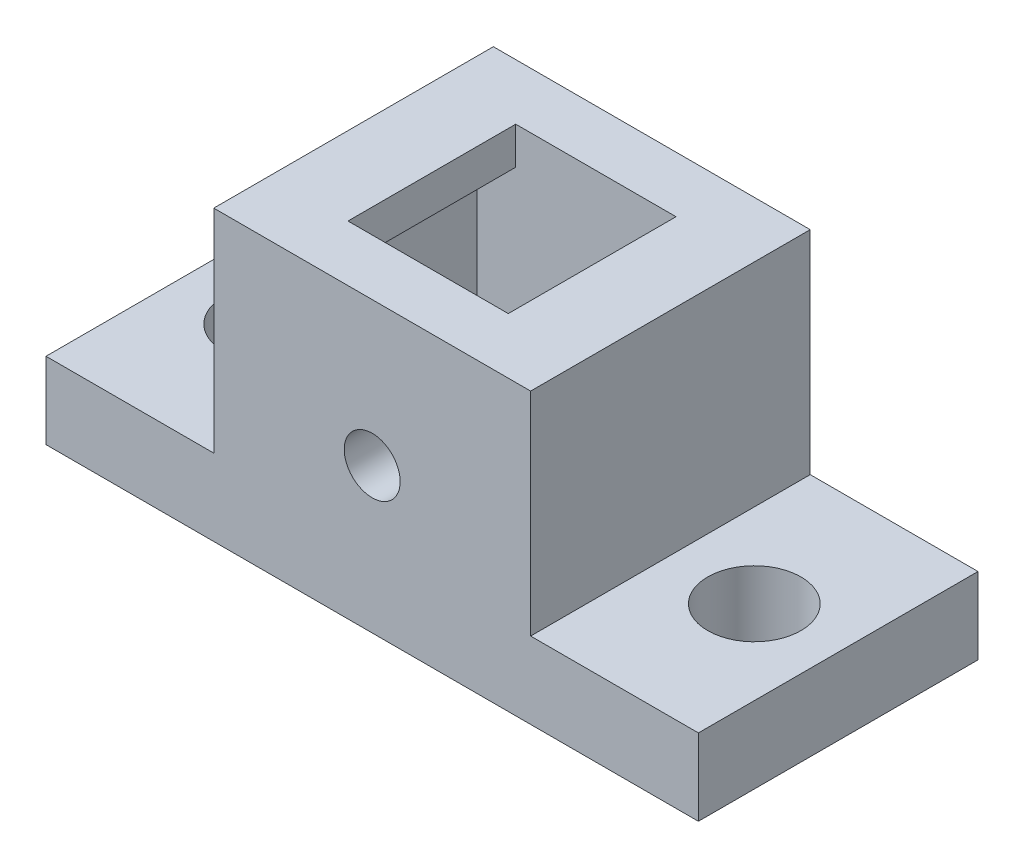
from build123d import *

# Parameters (mm, degrees)
SKETCH1_W           = 35
SKETCH1_H           = 15
BOSS_EXTRUDE1_DEPTH = 23.49
SKETCH2_W           = 22.56001237
SKETCH2_H           = 32.900224363
SKETCH2_W_2         = 23.005303498
CUT_EXTRUDE1_DEPTH  = 23.49
SKETCH3_W           = 17
SKETCH3_H           = 15.731554352
CUT_EXTRUDE2_DEPTH  = 23.49
SKETCH5_W           = 8.6
SKETCH5_H           = 9
CUT_EXTRUDE4_DEPTH  = 12.5
SKETCH8_W           = 12.842835289
SKETCH8_H           = 9
CUT_EXTRUDE5_DEPTH  = 10.5
SKETCH4_R           = 2.5
CUT_EXTRUDE6_DEPTH  = 5.107289171
SKETCH9_R           = 1.5
CUT_EXTRUDE7_DEPTH  = 16


with BuildPart() as part:
    # Sketch1 → Boss-Extrude1 (new body)
    with BuildSketch(Plane(origin=(0, 0, 0), x_dir=(1, 0, 0), z_dir=(0, 1, 0))):
        with Locations((17.5, 7.5)):
            Rectangle(SKETCH1_W, SKETCH1_H)
    extrude(amount=BOSS_EXTRUDE1_DEPTH)

    # Sketch2 → Cut-Extrude1 (cut)
    with BuildSketch(Plane.XY):
        with Locations((37.280006185, 20.557401353)):
            Rectangle(SKETCH2_W, SKETCH2_H)
        with Locations((-2.502651749, 20.557401353)):
            Rectangle(SKETCH2_W_2, SKETCH2_H)
    extrude(amount=-CUT_EXTRUDE1_DEPTH, mode=Mode.SUBTRACT)

    # Sketch3 → Cut-Extrude2 (cut)
    with BuildSketch(Plane.XY):
        with Locations((17.5, 23.355777176)):
            Rectangle(SKETCH3_W, SKETCH3_H)
    extrude(amount=-CUT_EXTRUDE2_DEPTH, mode=Mode.SUBTRACT)

    # Sketch5 → Cut-Extrude4 (cut)
    with BuildSketch(Plane(origin=(0, 15.49, 0), x_dir=(1, 0, 0), z_dir=(0, 1, 0))):
        with Locations((17.5, 7.5)):
            Rectangle(SKETCH5_W, SKETCH5_H)
    extrude(amount=-CUT_EXTRUDE4_DEPTH, mode=Mode.SUBTRACT)

    # Sketch8 → Cut-Extrude5 (cut)
    with BuildSketch(Plane(origin=(0, 2.99, 0), x_dir=(1, 0, 0), z_dir=(0, 1, 0))):
        with Locations((17.535477445, 7.5)):
            Rectangle(SKETCH8_W, SKETCH8_H)
    extrude(amount=CUT_EXTRUDE5_DEPTH, mode=Mode.SUBTRACT)

    # Sketch4 → Cut-Extrude6 (cut, through all)
    with BuildSketch(Plane(origin=(0, 4.107289171, 0), x_dir=(1, 0, 0), z_dir=(0, 1, 0))):
        with Locations((4.5, 7.5)):
            Circle(SKETCH4_R)
        with Locations((30.5, 7.5)):
            Circle(SKETCH4_R)
    extrude(amount=-CUT_EXTRUDE6_DEPTH, mode=Mode.SUBTRACT)

    # Sketch9 → Cut-Extrude7 (cut, through all)
    with BuildSketch(Plane.XY):
        with Locations((17.5, 7.780477446)):
            Circle(SKETCH9_R)
    extrude(amount=-CUT_EXTRUDE7_DEPTH, mode=Mode.SUBTRACT)


solid = part.part
